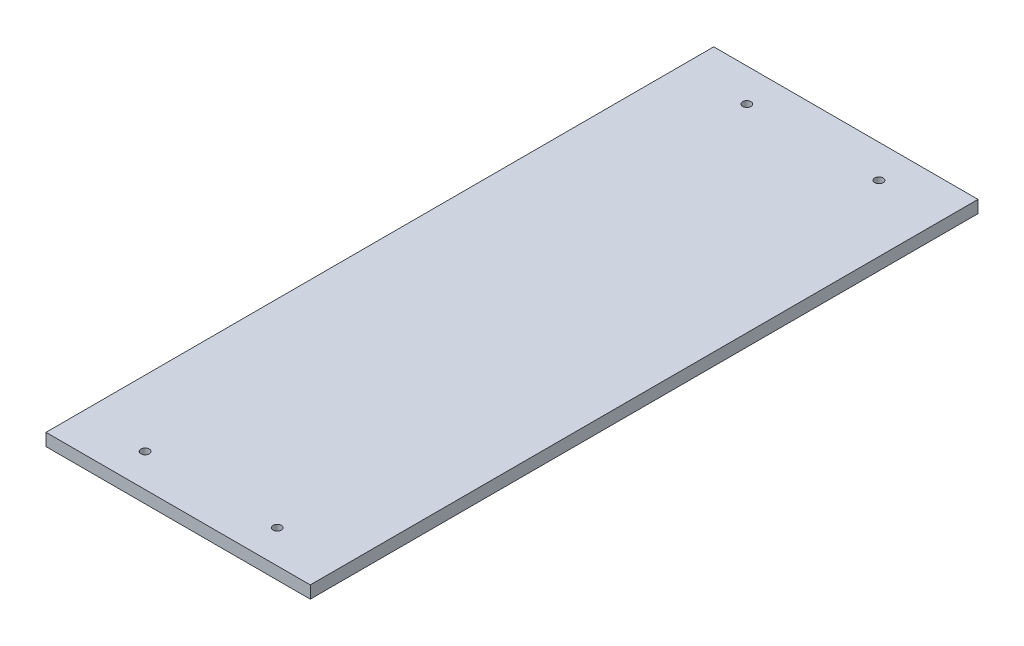
from build123d import *

# Parameters (mm, degrees)
SKETCH3_W           = 304.8
SKETCH3_H           = 609.6
BOSS_EXTRUDE1_DEPTH = 9.525
CUT_EXTRUDE1_DEPTH  = 15.24
SKETCH9_R           = 3.2258
CUT_EXTRUDE3_DEPTH  = 10.525
SKETCH10_W          = 18.645
SKETCH10_H          = 513.461
CUT_EXTRUDE4_DEPTH  = 41.656


with BuildPart() as part:
    # Sketch3 → Boss-Extrude1 (new body)
    with BuildSketch(Plane(origin=(0, 0, 0), x_dir=(1, 0, 0), z_dir=(0, 1, 0))):
        Rectangle(SKETCH3_W, SKETCH3_H)
    extrude(amount=-BOSS_EXTRUDE1_DEPTH)

    # Sketch4 → Cut-Extrude1 (cut)
    with BuildSketch(Plane(origin=(0, 0, 0), x_dir=(1, 0, 0), z_dir=(0, 1, 0))):
        Polygon((-152.4, 304.8), (152.4, 304.8), (152.4, 208.661), (152.4, -304.8), (120.245, -304.8), (120.245, 208.661), (-120.245, 208.661), (-120.245, -304.8), (-152.4, -304.8), (-152.4, 208.661), align=None)
    extrude(amount=-CUT_EXTRUDE1_DEPTH, mode=Mode.SUBTRACT)

    # Sketch9 → Cut-Extrude3 (cut, through all)
    with BuildSketch(Plane(origin=(0, -9.525, 0), x_dir=(-1, 0, 0), z_dir=(0, -1, 0))):
        with Locations((-50.83359, 183.261)):
            Circle(SKETCH9_R)
        with Locations((50.76641, 183.261)):
            Circle(SKETCH9_R)
        with Locations((50.76641, -279.4)):
            Circle(SKETCH9_R)
        with Locations((-50.83359, -279.4)):
            Circle(SKETCH9_R)
    extrude(amount=-CUT_EXTRUDE3_DEPTH, mode=Mode.SUBTRACT)

    # Sketch10 → Cut-Extrude4 (cut)
    with BuildSketch(Plane.XZ.offset(9.525)):
        with Locations((110.9225, 48.0695)):
            Rectangle(SKETCH10_W, SKETCH10_H)
        with Locations((-110.9225, 48.0695)):
            Rectangle(SKETCH10_W, SKETCH10_H)
    extrude(amount=-CUT_EXTRUDE4_DEPTH, mode=Mode.SUBTRACT)


solid = part.part
